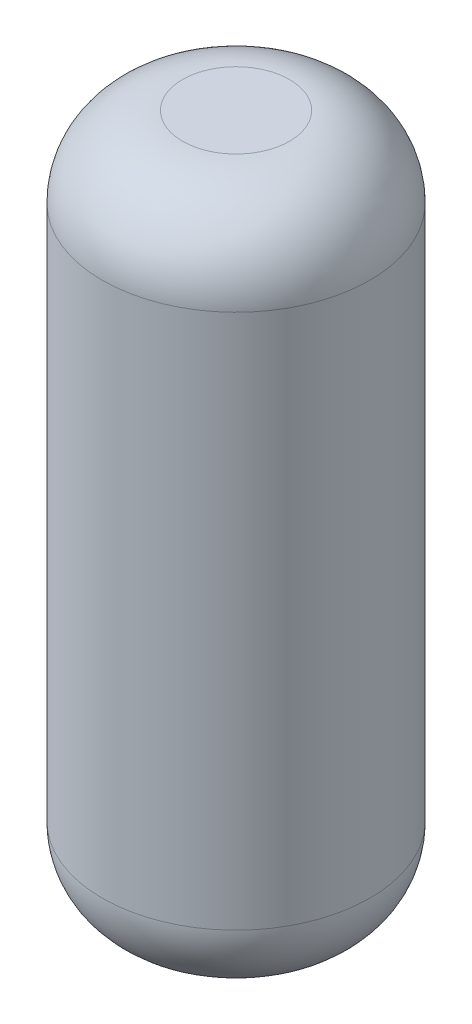
from build123d import *

# Parameters (mm, degrees)
CROQUIS1_R              = 5
SALIENTE_EXTRUIR1_DEPTH = 26
REDONDEO1_R             = 3


with BuildPart() as part:
    # Croquis1 → Saliente-Extruir1 (new body)
    with BuildSketch(Plane(origin=(0, 0, 0), x_dir=(1, 0, 0), z_dir=(0, 1, 0))):
        Circle(CROQUIS1_R)
    extrude(amount=SALIENTE_EXTRUIR1_DEPTH)

    # Redondeo1
    redondeo1_edges = [part.edges().sort_by_distance(p)[0] for p in [
        (-5, 0, 0),
        (-5, 26, 0),
    ]]
    fillet(redondeo1_edges, radius=REDONDEO1_R)


solid = part.part
